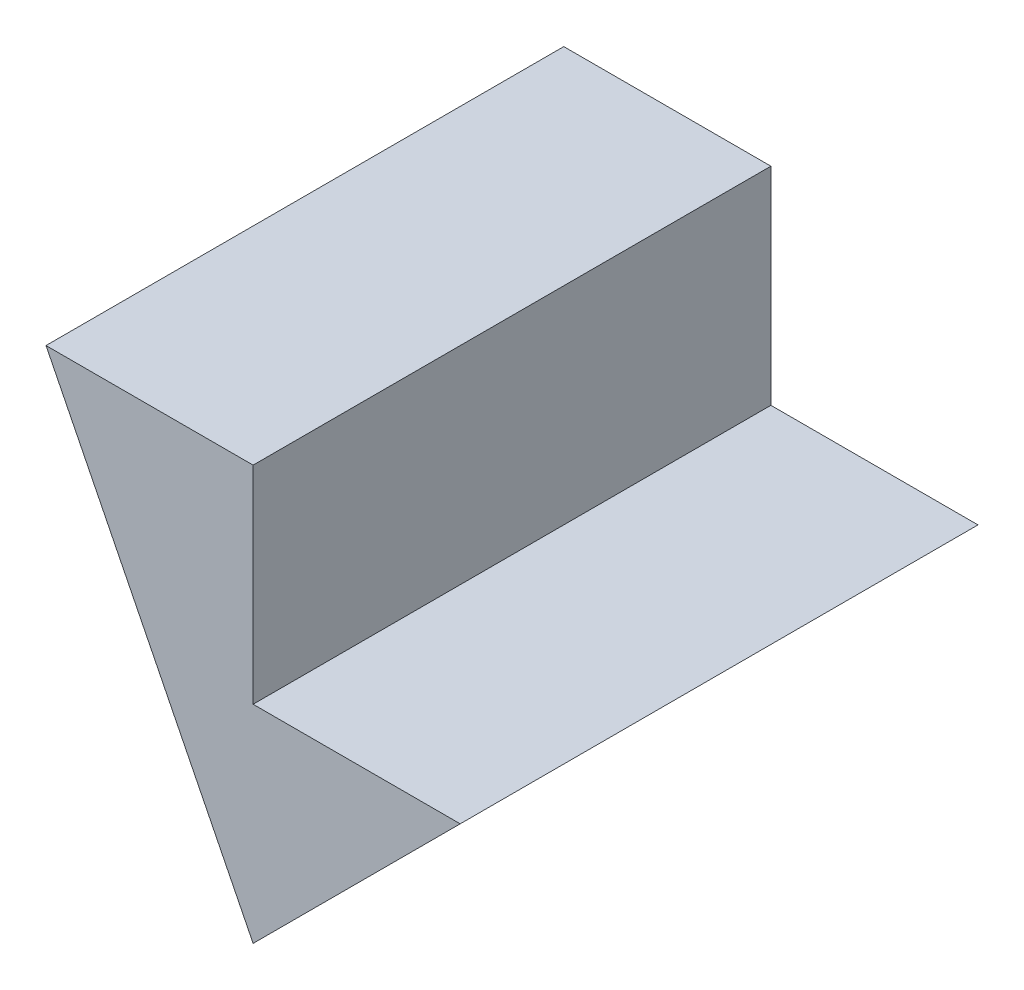
from build123d import *

# Parameters (mm, degrees)
BOSS_EXTRUDE2_DEPTH = 25


with BuildPart() as part:
    # Sketch1 → Boss-Extrude2 (new body)
    with BuildSketch(Plane.XY):
        Polygon((-10, 0), (0, 0), (0, -10), (10, -10), (0, -20), align=None)
    extrude(amount=BOSS_EXTRUDE2_DEPTH)


solid = part.part
